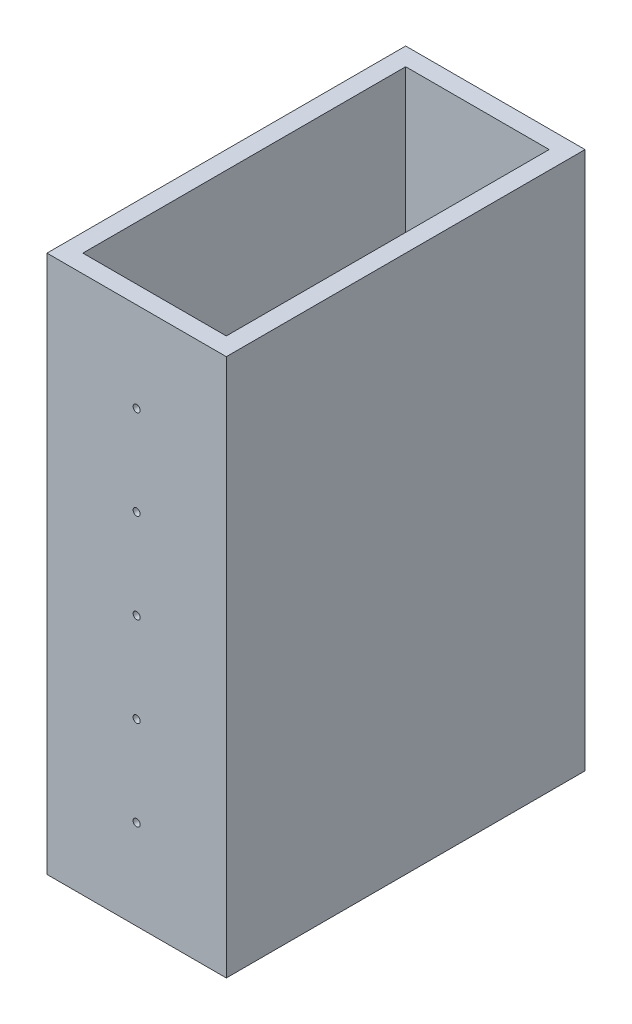
from build123d import *

# Parameters (mm, degrees)
SKETCH1_W           = 25.4
SKETCH1_H           = 50.8
SKETCH1_W_2         = 20.32
SKETCH1_H_2         = 45.72
BOSS_EXTRUDE1_DEPTH = 76.2
SKETCH2_R           = 0.5
CUT_EXTRUDE1_DEPTH  = 76.2


with BuildPart() as part:
    # Sketch1 → Boss-Extrude1 (new body)
    with BuildSketch(Plane(origin=(0, 0, 0), x_dir=(1, 0, 0), z_dir=(0, 1, 0))):
        with Locations((12.7, 25.4)):
            Rectangle(SKETCH1_W, SKETCH1_H)
        with Locations((12.7, 25.4)):
            Rectangle(SKETCH1_W_2, SKETCH1_H_2, mode=Mode.SUBTRACT)
    extrude(amount=BOSS_EXTRUDE1_DEPTH)

    # Sketch2 → Cut-Extrude1 (cut)
    with BuildSketch(Plane(origin=(0, 0, -50.8), x_dir=(-1, 0, 0), z_dir=(0, 0, -1))):
        with Locations((-12.7, 12.7)):
            Circle(SKETCH2_R)
        with Locations((-12.7, 25.4)):
            Circle(SKETCH2_R)
        with Locations((-12.7, 38.1)):
            Circle(SKETCH2_R)
        with Locations((-12.7, 50.8)):
            Circle(SKETCH2_R)
        with Locations((-12.7, 63.5)):
            Circle(SKETCH2_R)
    extrude(amount=-CUT_EXTRUDE1_DEPTH, mode=Mode.SUBTRACT)


solid = part.part
